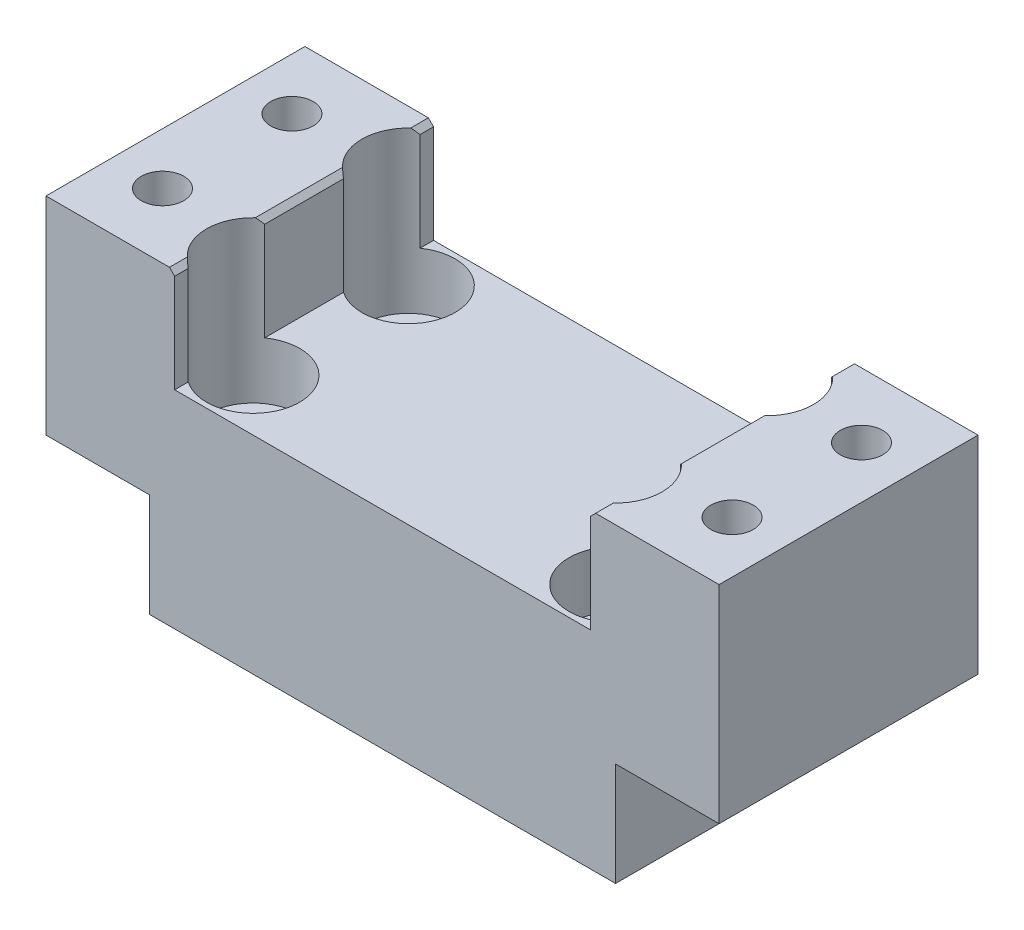
from build123d import *

# Parameters (mm, degrees)
SKETCH1_W               = 130
SKETCH1_H               = 50
BOSS_EXTRUDE1_DEPTH     = 60
SKETCH2_W               = 80.3
SKETCH2_H               = 40
CUT_EXTRUDE1_DEPTH      = 51
SKETCH3_R               = 4.1
CUT_EXTRUDE2_DEPTH      = 61
SKETCH4_R               = 8
CUT_EXTRUDE3_DEPTH      = 7
CHAMFER1_SIZE           = 1
SKETCH5_OUTSIDE_W       = 162.332
SKETCH5_OUTSIDE_H       = 82.332
SKETCH5_OUTSIDE_W_2     = 90
SKETCH5_OUTSIDE_H_2     = 50
CUT_EXTRUDE4_DEPTH      = 20
SKETCH6_R               = 4.1
CUT_EXTRUDE5_DEPTH      = 41
SKETCH7_R               = 9
CUT_EXTRUDE6_DEPTH      = 21
CUT_EXTRUDE6_DEPTH_BACK = 11


with BuildPart() as part:
    # Sketch1 → Boss-Extrude1 (new body)
    with BuildSketch(Plane(origin=(0, 0, 0), x_dir=(1, 0, 0), z_dir=(0, 1, 0))):
        Rectangle(SKETCH1_W, SKETCH1_H)
    extrude(amount=BOSS_EXTRUDE1_DEPTH)

    # Sketch2 → Cut-Extrude1 (cut, through all)
    with BuildSketch(Plane.XY.offset(25)):
        with Locations((0, 60)):
            Rectangle(SKETCH2_W, SKETCH2_H)
    extrude(amount=-CUT_EXTRUDE1_DEPTH, mode=Mode.SUBTRACT)

    # Sketch3 → Cut-Extrude2 (cut, through all)
    with BuildSketch(Plane.XZ):
        with Locations((-35, 15)):
            Circle(SKETCH3_R)
        with Locations((-35, -15)):
            Circle(SKETCH3_R)
        with Locations((35, -14.217273236)):
            Circle(SKETCH3_R)
        with Locations((35, 15)):
            Circle(SKETCH3_R)
    extrude(amount=-CUT_EXTRUDE2_DEPTH, mode=Mode.SUBTRACT)

    # Sketch4 → Cut-Extrude3 (cut)
    with BuildSketch(Plane.XZ):
        with Locations((35, 15)):
            Circle(SKETCH4_R)
        with Locations((35, -14.217273236)):
            Circle(SKETCH4_R)
        with Locations((-35, 15)):
            Circle(SKETCH4_R)
        with Locations((-35, -15)):
            Circle(SKETCH4_R)
    extrude(amount=-CUT_EXTRUDE3_DEPTH, mode=Mode.SUBTRACT)

    # Chamfer1
    chamfer1_edges = [part.edges().sort_by_distance(p)[0] for p in [
        (40.15, 60, 0),
        (-40.15, 60, 0),
    ]]
    chamfer(chamfer1_edges, length=CHAMFER1_SIZE)

    # Sketch5 outside → Cut-Extrude4 (cut)
    with BuildSketch(Plane.XZ):
        Rectangle(SKETCH5_OUTSIDE_W, SKETCH5_OUTSIDE_H)
        Rectangle(SKETCH5_OUTSIDE_W_2, SKETCH5_OUTSIDE_H_2, mode=Mode.SUBTRACT)
    extrude(amount=-CUT_EXTRUDE4_DEPTH, mode=Mode.SUBTRACT)

    # Sketch6 → Cut-Extrude5 (cut, through all)
    with BuildSketch(Plane.XZ.offset(-20)):
        with Locations((55, -12.5)):
            Circle(SKETCH6_R)
        with Locations((55, 12.5)):
            Circle(SKETCH6_R)
        with Locations((-55, -12.5)):
            Circle(SKETCH6_R)
        with Locations((-55, 12.5)):
            Circle(SKETCH6_R)
    extrude(amount=-CUT_EXTRUDE5_DEPTH, mode=Mode.SUBTRACT)

    # Sketch7 → Cut-Extrude6 (cut, two sides)
    with BuildSketch(Plane(origin=(0, 40, 0), x_dir=(1, 0, 0), z_dir=(0, 1, 0))) as cut_extrude6_sk:
        with Locations((35, -15)):
            Circle(SKETCH7_R)
        with Locations((-35, -15)):
            Circle(SKETCH7_R)
        with Locations((35, 14.217273236)):
            Circle(SKETCH7_R)
        with Locations((-35, 15)):
            Circle(SKETCH7_R)
    extrude(amount=CUT_EXTRUDE6_DEPTH, mode=Mode.SUBTRACT)
    extrude(cut_extrude6_sk.sketch, amount=-CUT_EXTRUDE6_DEPTH_BACK, mode=Mode.SUBTRACT)


solid = part.part
